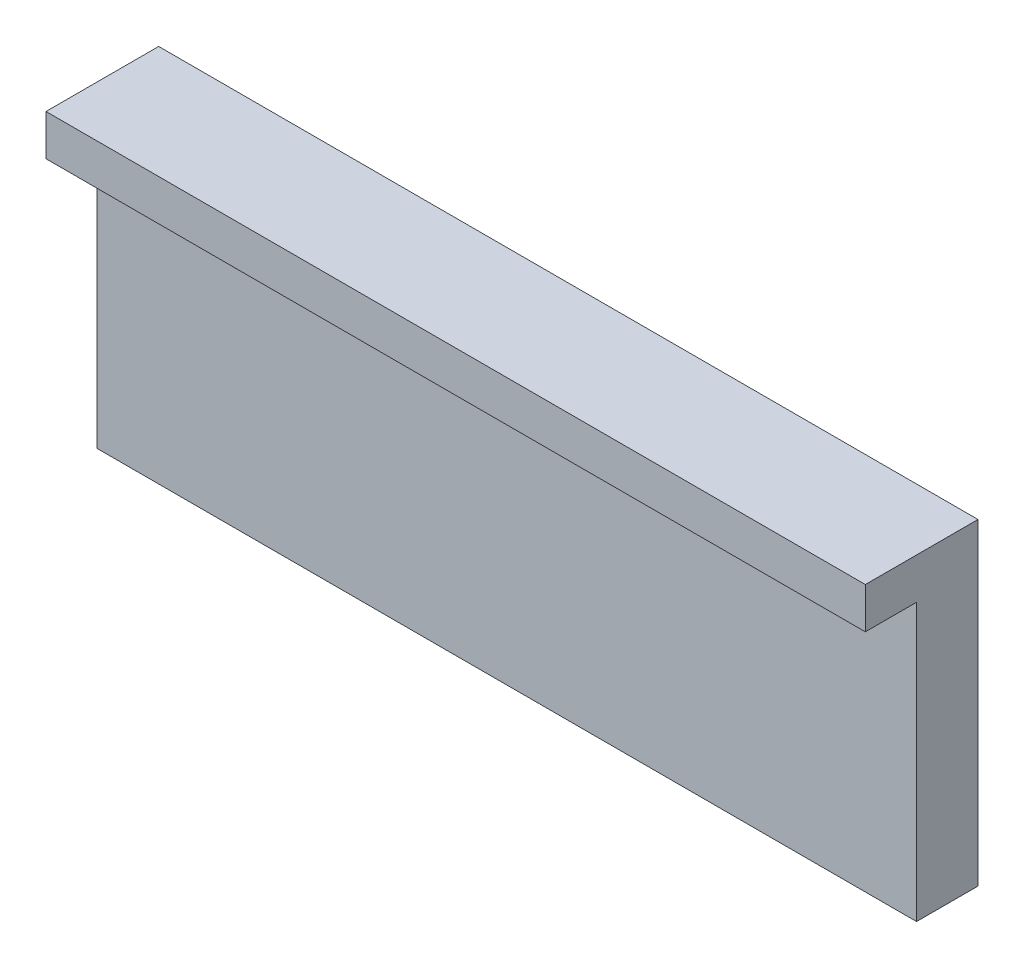
from build123d import *

# Parameters (mm, degrees)
CROQUIS1_W              = 80
CROQUIS1_H              = 31
SALIENTE_EXTRUIR1_DEPTH = 6
CROQUIS2_W              = 80
CROQUIS2_H              = 4
SALIENTE_EXTRUIR2_DEPTH = 5


with BuildPart() as part:
    # Croquis1 → Saliente-Extruir1 (new body)
    with BuildSketch(Plane.XY):
        with Locations((40, 15.5)):
            Rectangle(CROQUIS1_W, CROQUIS1_H)
    extrude(amount=SALIENTE_EXTRUIR1_DEPTH)

    # Croquis2 → Saliente-Extruir2 (add)
    with BuildSketch(Plane.XY.offset(6)):
        with Locations((40, 29)):
            Rectangle(CROQUIS2_W, CROQUIS2_H)
    extrude(amount=SALIENTE_EXTRUIR2_DEPTH)


solid = part.part
